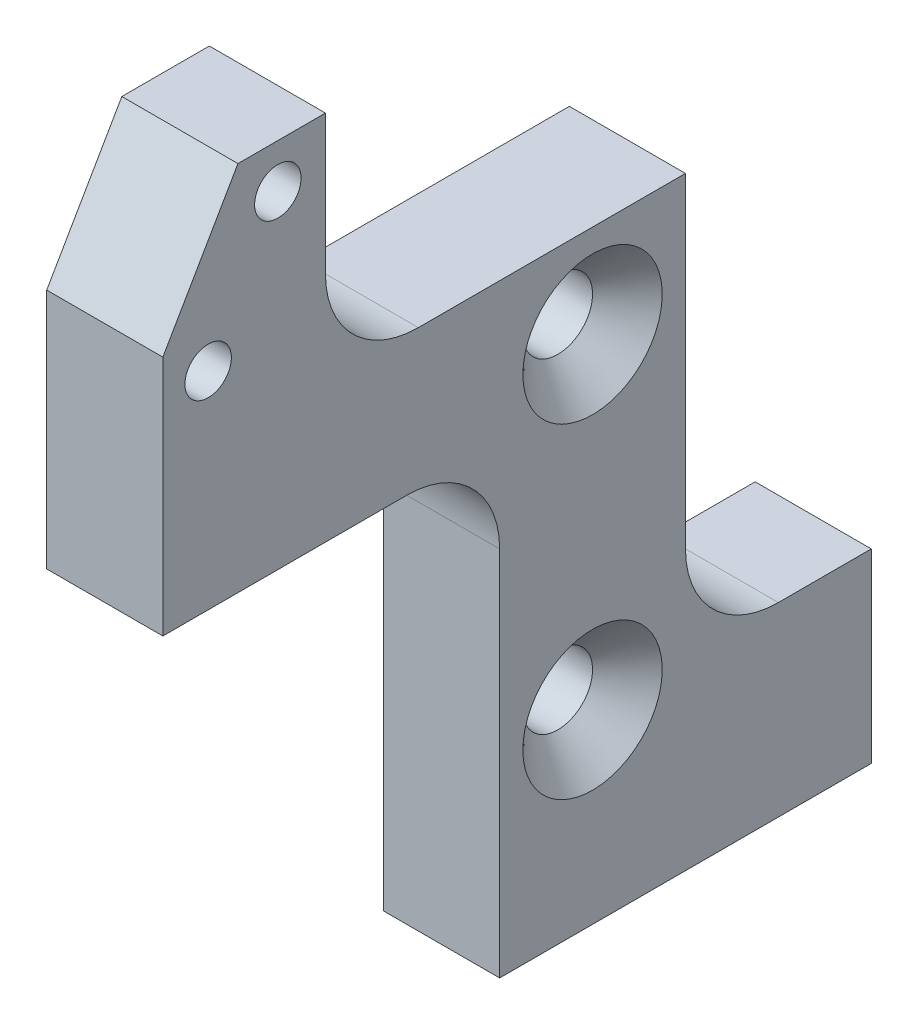
from build123d import *

# Parameters (mm, degrees)
SKETCH1_R                       = 1.5
SKETCH1_R_2                     = 1
BOSS_EXTRUDE1_DEPTH             = 5
FILLET1_R                       = 4
TAP_DRILL_FOR_M3X0_5_TAP1_D     = 2.5
TAP_DRILL_FOR_M3X0_5_TAP1_DEPTH = 4
CHAMFER1_SIZE                   = 1.5


with BuildPart() as part:
    # Sketch1 → Boss-Extrude1 (new body)
    with BuildSketch(Plane(origin=(0, 0, 0), x_dir=(0, 0, -1), z_dir=(1, 0, 0))):
        Polygon((30.5, 0), (14.5, 0), (14.5, 20), (0, 20), (0, 30.4), (3.233161507, 36), (7, 36), (7, 26), (22.5, 26), (22.5, 8), (30.5, 8), align=None)
        with Locations((18.5, 8)):
            Circle(SKETCH1_R, mode=Mode.SUBTRACT)
        with Locations((18.5, 22)):
            Circle(SKETCH1_R, mode=Mode.SUBTRACT)
        with Locations((1.95, 28.91)):
            Circle(SKETCH1_R_2, mode=Mode.SUBTRACT)
        with Locations((4.95, 34.106152423)):
            Circle(SKETCH1_R_2, mode=Mode.SUBTRACT)
    extrude(amount=BOSS_EXTRUDE1_DEPTH)

    # Fillet1
    fillet1_edges = [part.edges().sort_by_distance(p)[0] for p in [
        (2.5, 20, -14.5),
        (2.5, 26, -7),
        (2.5, 8, -22.5),
    ]]
    fillet(fillet1_edges, radius=FILLET1_R)

    # Tap Drill for M3x0.5 Tap1
    with Locations(Plane(origin=(0, 0, 0), x_dir=(-1, 0, 0), z_dir=(0, -1, 0))):
        with Locations((-2.5, 17.5), (-2.5, 27.5)):
            Hole(TAP_DRILL_FOR_M3X0_5_TAP1_D / 2, depth=TAP_DRILL_FOR_M3X0_5_TAP1_DEPTH)

    # Chamfer1
    chamfer1_edges = [part.edges().sort_by_distance(p)[0] for p in [
        (5, 8, -17),
        (5, 22, -17),
    ]]
    chamfer(chamfer1_edges, length=CHAMFER1_SIZE)


solid = part.part
